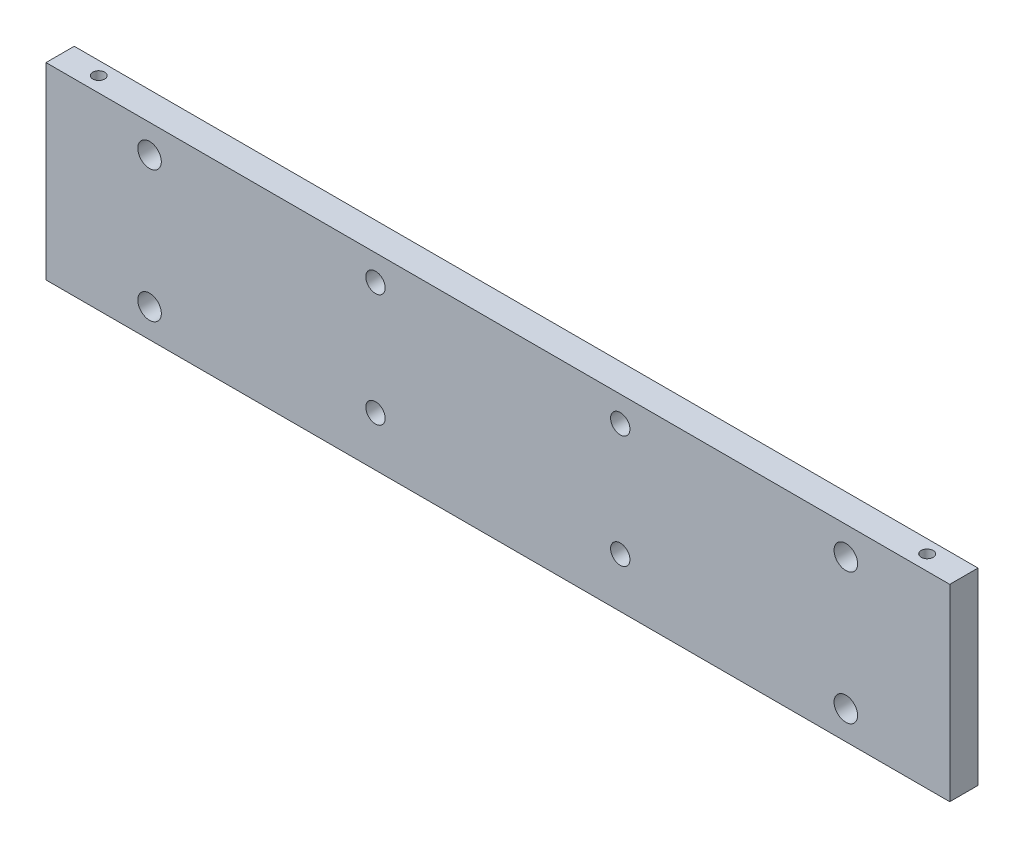
from build123d import *

# Parameters (mm, degrees)
SKETCH1_W                      = 304.8
SKETCH1_H                      = 63.5
BOSS_EXTRUDE1_DEPTH            = 9.525
F_5_16_18_TAPPED_HOLE1_D       = 6.5278
F_5_16_0_3125_DIAMETER_HOLE1_D = 7.9375
F_10_32_TAPPED_HOLE1_D         = 4.0386
F_10_32_TAPPED_HOLE1_DEPTH     = 11.938
F_10_32_TAPPED_HOLE1_TIP       = 1.213317848


with BuildPart() as part:
    # Sketch1 → Boss-Extrude1 (new body)
    with BuildSketch(Plane.XY):
        Rectangle(SKETCH1_W, SKETCH1_H)
    extrude(amount=BOSS_EXTRUDE1_DEPTH)

    # 5/16-18 Tapped Hole1 (through all)
    with Locations(Plane(origin=(-41.275, 23.114, 9.525), x_dir=(1, 0, 0), z_dir=(0, 0, 1))):
        with Locations((0, 0), (82.55, 0), (82.55, -38.1), (0, -38.1)):
            Hole(F_5_16_18_TAPPED_HOLE1_D / 2)

    # 5/16 (0.3125) Diameter Hole1 (through all)
    with Locations(Plane(origin=(-117.475, 22.225, 9.525), x_dir=(1, 0, 0), z_dir=(0, 0, 1))):
        with Locations((0, 0), (0, -44.323), (234.823, -44.323), (234.823, 0)):
            Hole(F_5_16_0_3125_DIAMETER_HOLE1_D / 2)

    # #10-32 Tapped Hole1
    with Locations(Plane(origin=(-139.7, 31.75, 4.445), x_dir=(0, 0, 1), z_dir=(0, 1, 0))):
        with Locations((0, 0), (0, 279.4)):
            Hole(F_10_32_TAPPED_HOLE1_D / 2, depth=F_10_32_TAPPED_HOLE1_DEPTH)
            with Locations((0, 0, -(F_10_32_TAPPED_HOLE1_DEPTH + F_10_32_TAPPED_HOLE1_TIP / 2))):  # 118° drill point
                Cone(0, F_10_32_TAPPED_HOLE1_D / 2, F_10_32_TAPPED_HOLE1_TIP, mode=Mode.SUBTRACT)


solid = part.part
